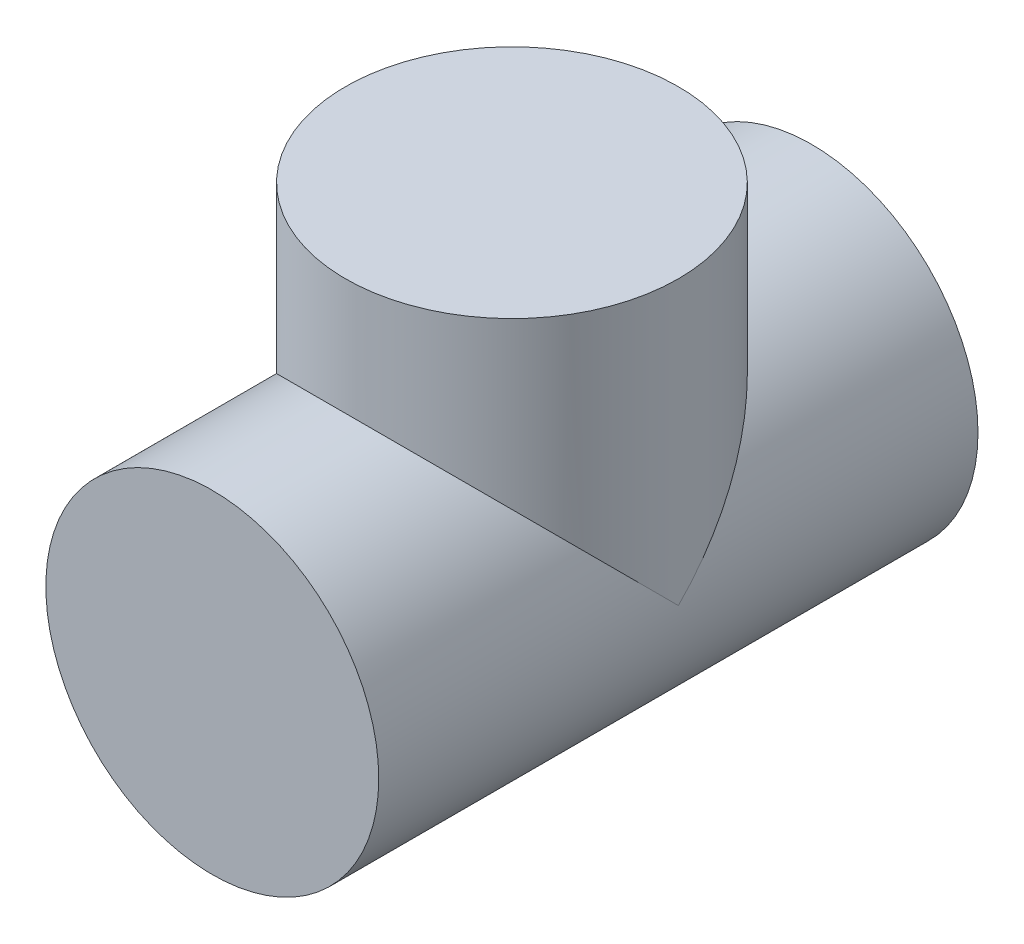
from build123d import *

# Parameters (mm, degrees)
SKETCH2_R = 50


with BuildPart() as part:
    # Sweep1: sweep along a path in Sketch1
    with BuildLine(Plane(origin=(0, 0, 0), x_dir=(0, 0, -1), z_dir=(1, 0, 0))) as sweep1_path:
        Line((-45, 0), (45, 0))
        Line((45, 0), (45, 85))
    # Sketch2 → Sweep1 (sweep)
    with BuildSketch(Plane.XY.offset(45)):
        Circle(SKETCH2_R)
    sweep1 = sweep(path=sweep1_path.line, transition=Transition.RIGHT)

    # Mirror2: Sweep1 across plane
    add(sweep1.mirror(Plane.XY.offset(-45)))


solid = part.part
